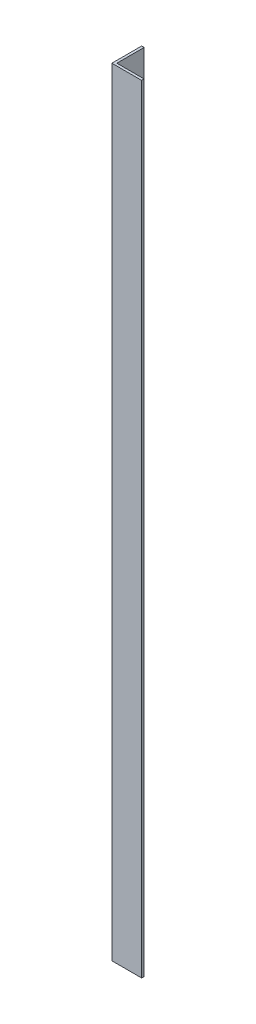
from build123d import *

# Parameters (mm, degrees)
BOSS_EXTRUDE1_DEPTH = 500


with BuildPart() as part:
    # Sketch1 → Boss-Extrude1 (new body)
    with BuildSketch(Plane(origin=(0, 0, 0), x_dir=(1, 0, 0), z_dir=(0, 1, 0))):
        Polygon((0, 0), (0, 19.15), (1.6, 19.15), (1.6, 1.6), (19.15, 1.6), (19.15, 0), align=None)
    extrude(amount=BOSS_EXTRUDE1_DEPTH)


solid = part.part
